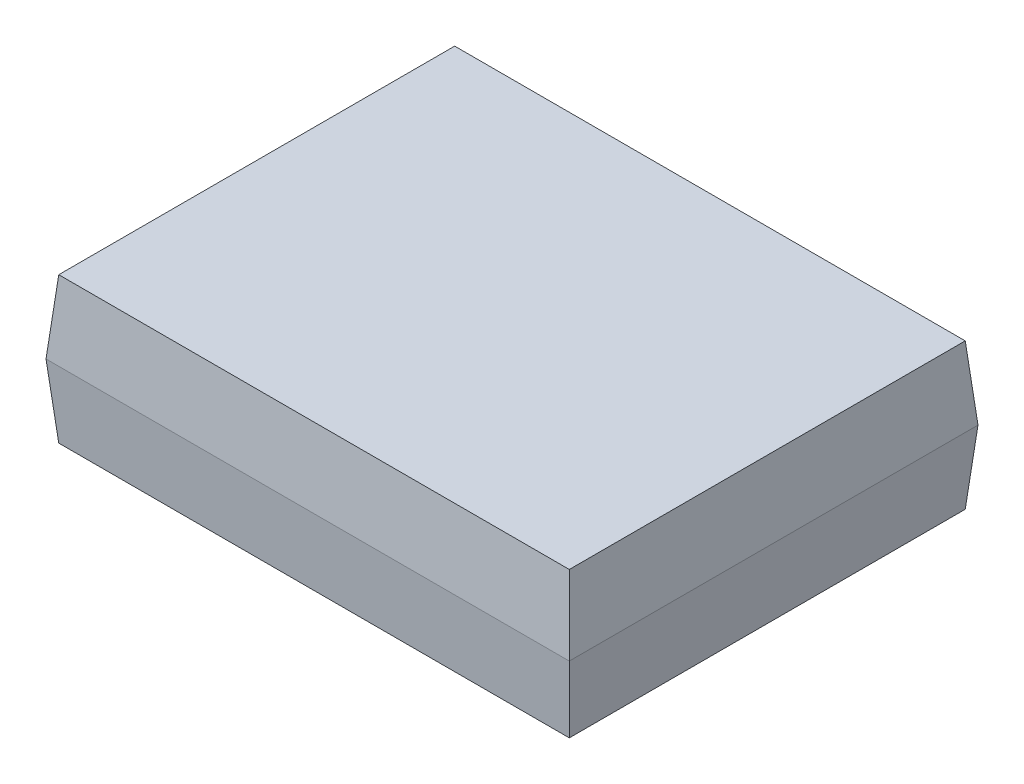
from build123d import *

# Parameters (mm, degrees)
ESQUISSE1_W        = 4.9
ESQUISSE1_H        = 3.8
BOSS_EXTRU_1_DEPTH = 0.7
BOSS_EXTRU_1_TAPER = -5
ESQUISSE2_W        = 5.022484128
ESQUISSE2_H        = 3.922484128
BOSS_EXTRU_2_DEPTH = 0.7
BOSS_EXTRU_2_TAPER = 5


with BuildPart() as part:
    # Esquisse1 → Boss.-Extru.1 (new body)
    with BuildSketch(Plane(origin=(0, 0, 0), x_dir=(1, 0, 0), z_dir=(0, 1, 0))):
        with Locations((2.45, 1.9)):
            Rectangle(ESQUISSE1_W, ESQUISSE1_H)
    extrude(amount=BOSS_EXTRU_1_DEPTH, taper=BOSS_EXTRU_1_TAPER)

    # Esquisse2 → Boss.-Extru.2 (add)
    with BuildSketch(Plane(origin=(0, 0.7, 0), x_dir=(1, 0, 0), z_dir=(0, 1, 0))):
        with Locations((2.45, 1.9)):
            Rectangle(ESQUISSE2_W, ESQUISSE2_H)
    extrude(amount=BOSS_EXTRU_2_DEPTH, taper=BOSS_EXTRU_2_TAPER)


solid = part.part
